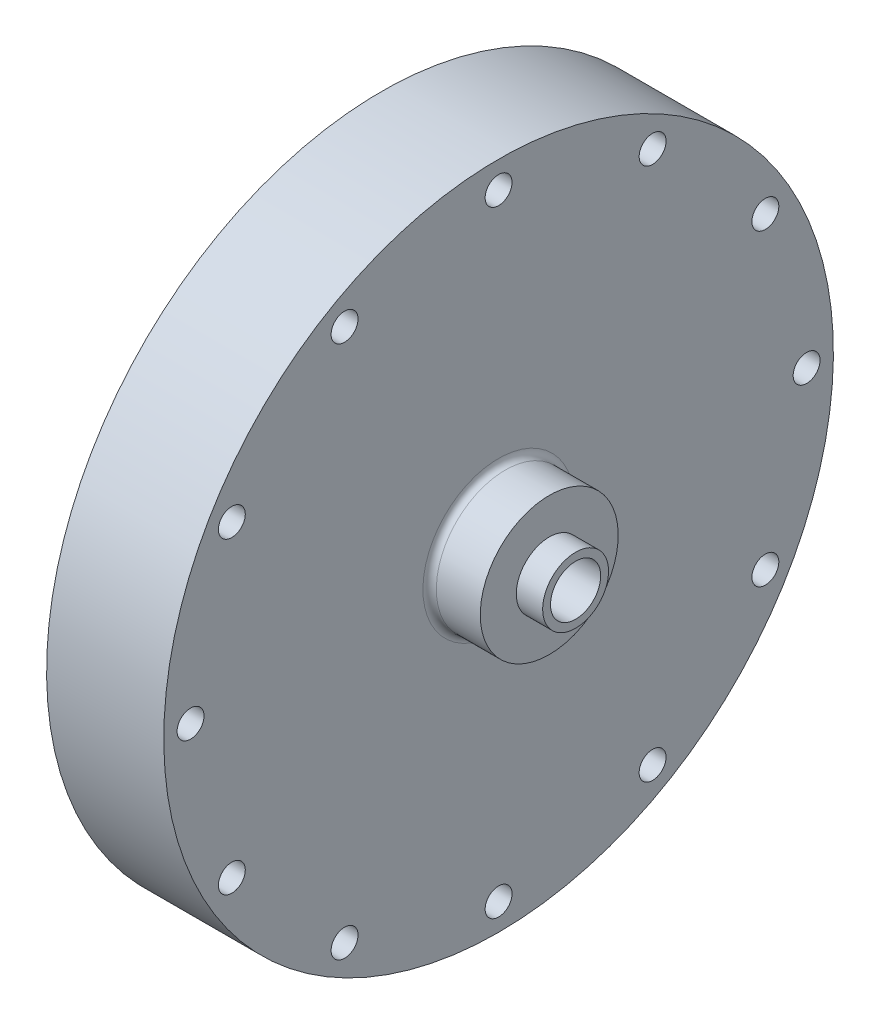
from build123d import *

# Parameters (mm, degrees)
SKETCH3_R                 = 4.7625
OXIDIZER_INLET_HOLE_DEPTH = 37.83
FLANGE_HOLES_D            = 5.1054
FLANGE_HOLES_DEPTH        = 22.225
DOWEL_HOLES_D             = 4.7625
DOWEL_HOLES_DEPTH         = 6.35
DOWEL_HOLES_TIP           = 1.430799349
SKETCH12_R                = 28.575
CUT_EXTRUDE2_DEPTH        = 9.525
SKETCH16_R                = 28.575
SKETCH17_R                = 4.7625
CIRPATTERN1_COUNT         = 8
FILLET1_R                 = 1.27


with BuildPart() as part:
    # Sketch2 → Main Structure (revolve)
    with BuildSketch(Plane.XY):
        Polygon((41.355, 13.081), (41.355, 6.2484), (46.355, 6.2484), (46.355, 0), (9.525, 0), (9.525, 63.5), (31.75, 63.5), (31.75, 13.081), align=None)
    revolve(axis=Axis((9.525, 0, 0), (1, 0, 0)))

    # Sketch3 → Oxidizer Inlet Hole (cut, through all)
    with BuildSketch(Plane(origin=(46.355, 0, 0), x_dir=(0, 0, -1), z_dir=(1, 0, 0))):
        Circle(SKETCH3_R)
    extrude(amount=-OXIDIZER_INLET_HOLE_DEPTH, mode=Mode.SUBTRACT)

    # Flange Holes
    with Locations(Plane(origin=(31.75, 0, 0), x_dir=(0, 0, 1), z_dir=(1, 0, 0))):
        with Locations((0, 58.42), (-29.21, 50.593204089), (-50.593204089, 29.21), (-58.42, 0), (-50.593204089, -29.21), (-29.21, -50.593204089), (0, -58.42), (29.21, -50.593204089), (50.593204089, -29.21), (58.42, 0), (50.593204089, 29.21), (29.21, 50.593204089)):
            Hole(FLANGE_HOLES_D / 2, depth=FLANGE_HOLES_DEPTH)

    # Dowel Holes
    with Locations(Plane.ZY.offset(-9.525)):
        with Locations((56.429386772, -15.120208615), (-56.429386772, 15.120208615)):
            Hole(DOWEL_HOLES_D / 2, depth=DOWEL_HOLES_DEPTH)
            with Locations((0, 0, -(DOWEL_HOLES_DEPTH + DOWEL_HOLES_TIP / 2))):  # 118° drill point
                Cone(0, DOWEL_HOLES_D / 2, DOWEL_HOLES_TIP, mode=Mode.SUBTRACT)

    # Sketch12 → Cut-Extrude2 (cut)
    with BuildSketch(Plane.ZY.offset(-9.525)):
        Circle(SKETCH12_R)
    extrude(amount=-CUT_EXTRUDE2_DEPTH, mode=Mode.SUBTRACT)

    # Sketch16 → Internal Flow Path Loft Cut section 0
    with BuildSketch(Plane.ZY.offset(-19.05)):
        Circle(SKETCH16_R)
    # Sketch17 → Internal Flow Path Loft Cut section 1
    with BuildSketch(Plane.ZY.offset(-30.48)):
        Circle(SKETCH17_R)
    loft(mode=Mode.SUBTRACT)

    # Sketch20 → #4-40 Tapped Hole1 (revolve, cut)
    with BuildSketch(Plane(origin=(9.525, 0, 33.3375), x_dir=(0, 0, 1), z_dir=(0, 1, 0))):
        Polygon((0, 0), (0, 13.887152758), (1.1303, 13.208), (1.1303, 0), align=None)
    f_4_40_tapped_hole1 = revolve(axis=Axis((3.175, 0, 33.3375), (1, 0, 0)), mode=Mode.SUBTRACT)

    # CirPattern1: #4-40 Tapped Hole1 ×8 about axis
    cirpattern1_axis = Axis((0, 0, 0), (1, 0, 0))
    for i in range(1, CIRPATTERN1_COUNT):
        add(f_4_40_tapped_hole1.rotate(cirpattern1_axis, i * 360 / CIRPATTERN1_COUNT), mode=Mode.SUBTRACT)

    # Fillet1
    fillet1_edges = [part.edges().sort_by_distance(p)[0] for p in [
        (31.75, -13.081, 0),
    ]]
    fillet(fillet1_edges, radius=FILLET1_R)


solid = part.part
